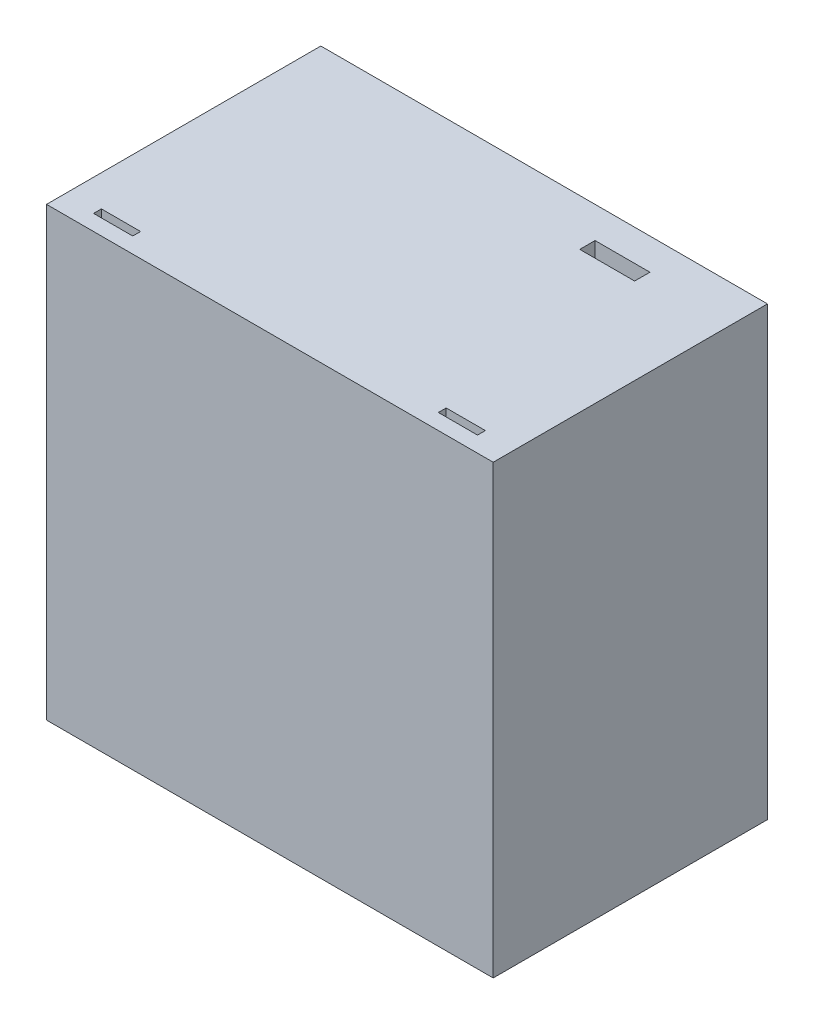
from build123d import *

# Parameters (mm, degrees)
SKETCH2_W           = 57
SKETCH2_H           = 57
BOSS_EXTRUDE1_DEPTH = 35
SKETCH3_W           = 5
SKETCH3_H           = 1
CUT_EXTRUDE1_DEPTH  = 60
SKETCH4_W           = 49.5
SKETCH4_H           = 49.5
CUT_EXTRUDE2_DEPTH  = 28
CUT_EXTRUDE4_DEPTH  = 5
CUT_EXTRUDE5_DEPTH  = 10
SKETCH13_W          = 7
SKETCH13_H          = 1.952566844
CUT_EXTRUDE8_DEPTH  = 12


with BuildPart() as part:
    # Sketch2 → Boss-Extrude1 (new body)
    with BuildSketch(Plane.XY):
        with Locations((-5.733009709, -0.737864078)):
            Rectangle(SKETCH2_W, SKETCH2_H)
    extrude(amount=BOSS_EXTRUDE1_DEPTH)

    # Sketch3 → Cut-Extrude1 (cut)
    with BuildSketch(Plane(origin=(0, 27.762135922, 0), x_dir=(1, 0, 0), z_dir=(0, 1, 0))):
        with Locations((-27.733009709, -32.5)):
            Rectangle(SKETCH3_W, SKETCH3_H)
        with Locations((16.266990291, -32.5)):
            Rectangle(SKETCH3_W, SKETCH3_H)
    extrude(amount=-CUT_EXTRUDE1_DEPTH, mode=Mode.SUBTRACT)

    # Sketch4 → Cut-Extrude2 (cut)
    with BuildSketch(Plane(origin=(0, 0, 0), x_dir=(-1, 0, 0), z_dir=(0, 0, -1))):
        with Locations((5.733009709, -0.737864078)):
            Rectangle(SKETCH4_W, SKETCH4_H)
    extrude(amount=-CUT_EXTRUDE2_DEPTH, mode=Mode.SUBTRACT)

    # Sketch5 → Cut-Extrude4 (cut)
    with BuildSketch(Plane(origin=(0, -25.487864078, 0), x_dir=(1, 0, 0), z_dir=(0, 1, 0))):
        with BuildLine():
            Line((2.766990291, -12), (2.766990291, 0))
            Line((2.766990291, 0), (-14.233009709, 0))
            Line((-14.233009709, 0), (-14.233009709, -12))
            ThreePointArc((-14.233009709, -12), (-5.733009709, -20.5), (2.766990291, -12))
        make_face()
    extrude(amount=-CUT_EXTRUDE4_DEPTH, mode=Mode.SUBTRACT)

    # Sketch7 → Cut-Extrude5 (cut)
    with BuildSketch(Plane(origin=(-30.483009709, 0, 0), x_dir=(0, 0, -1), z_dir=(1, 0, 0))):
        with BuildLine():
            Line((-12, -9.237864078), (0, -9.237864078))
            Line((0, -9.237864078), (0, 7.762135922))
            Line((0, 7.762135922), (-12, 7.762135922))
            ThreePointArc((-12, 7.762135922), (-20.5, -0.737864078), (-12, -9.237864078))
        make_face()
    extrude(amount=-CUT_EXTRUDE5_DEPTH, mode=Mode.SUBTRACT)

    # Sketch13 → Cut-Extrude8 (cut)
    with BuildSketch(Plane(origin=(0, 27.762135922, 0), x_dir=(1, 0, 0), z_dir=(0, 1, 0))):
        with Locations((8.266990291, -4.976283422)):
            Rectangle(SKETCH13_W, SKETCH13_H)
    extrude(amount=-CUT_EXTRUDE8_DEPTH, mode=Mode.SUBTRACT)


solid = part.part
